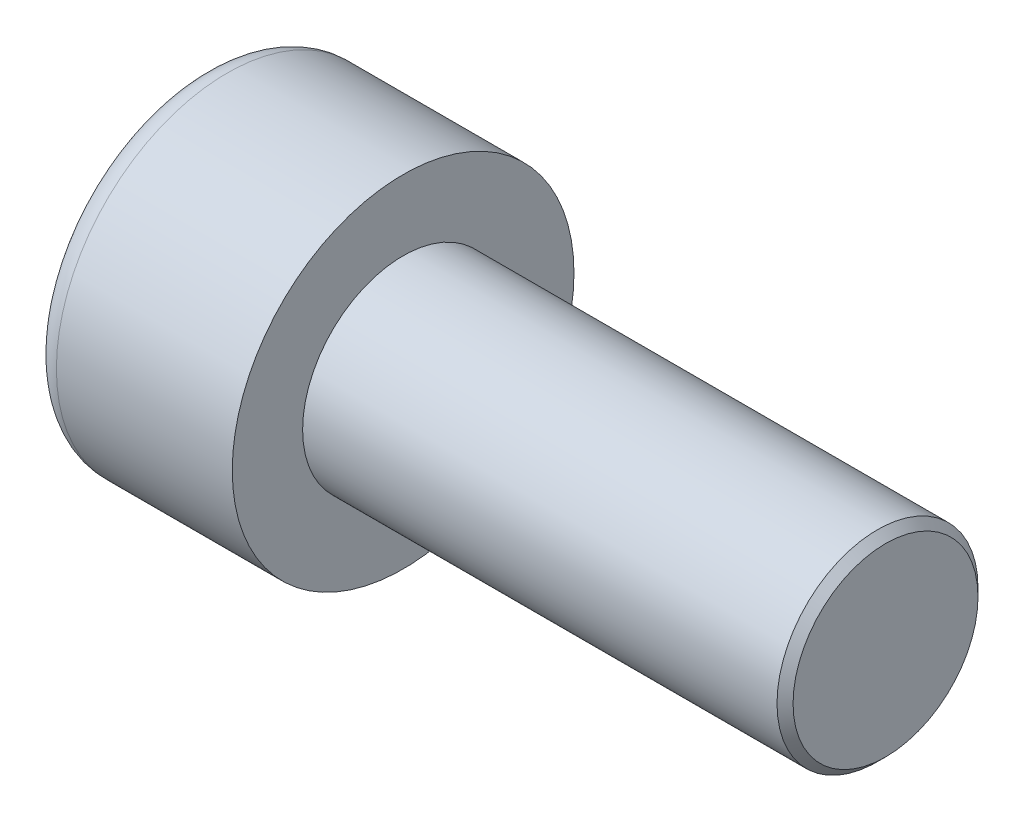
from build123d import *

# Parameters (mm, degrees)
SKETCH1_R           = 4.25
BASEHEAD_DEPTH      = 5
SKETCH2_R           = 2.5
BASEBODY_DEPTH      = 12
HEXAGONSOCKET_DEPTH = 2.5
TOPFILLET_R         = 0.625
CHAMFER1_SIZE       = 0.2


with BuildPart() as part:
    # Sketch1 → BaseHead (new body)
    with BuildSketch(Plane(origin=(0, 0, 0), x_dir=(0, 0, -1), z_dir=(1, 0, 0))):
        Circle(SKETCH1_R)
    extrude(amount=BASEHEAD_DEPTH)

    # Sketch2 → BaseBody (add)
    with BuildSketch(Plane(origin=(5, 0, 0), x_dir=(0, 0, -1), z_dir=(1, 0, 0))):
        Circle(SKETCH2_R)
    extrude(amount=BASEBODY_DEPTH)

    # Sketch3 → HexagonSocket (cut)
    with BuildSketch(Plane(origin=(0, 0, 0), x_dir=(0, 0, -1), z_dir=(1, 0, 0))):
        Polygon((2.309401077, 0), (1.154700538, 2), (-1.154700538, 2), (-2.309401077, 0), (-1.154700538, -2), (1.154700538, -2), align=None)
    extrude(amount=HEXAGONSOCKET_DEPTH, mode=Mode.SUBTRACT)

    # Sketch4 → Cut-Revolve1 (revolve, cut)
    with BuildSketch(Plane(origin=(-4.19613823, 0.75, 0), x_dir=(-1, 0, 0), z_dir=(0, 0, 1))):
        Polygon((-6.69613823, 2.75), (-7.850838768, 0.75), (-6.69613823, 0.75), align=None)
    revolve(axis=Axis((0.838992387, 0, 0), (-1, 0, 0)), mode=Mode.SUBTRACT)

    # TopFillet
    topfillet_edges = [part.edges().sort_by_distance(p)[0] for p in [
        (0, 0, 4.25),
    ]]
    fillet(topfillet_edges, radius=TOPFILLET_R)

    # Chamfer1
    chamfer1_edges = [part.edges().sort_by_distance(p)[0] for p in [
        (17, 0, 2.5),
    ]]
    chamfer(chamfer1_edges, length=CHAMFER1_SIZE)


solid = part.part
